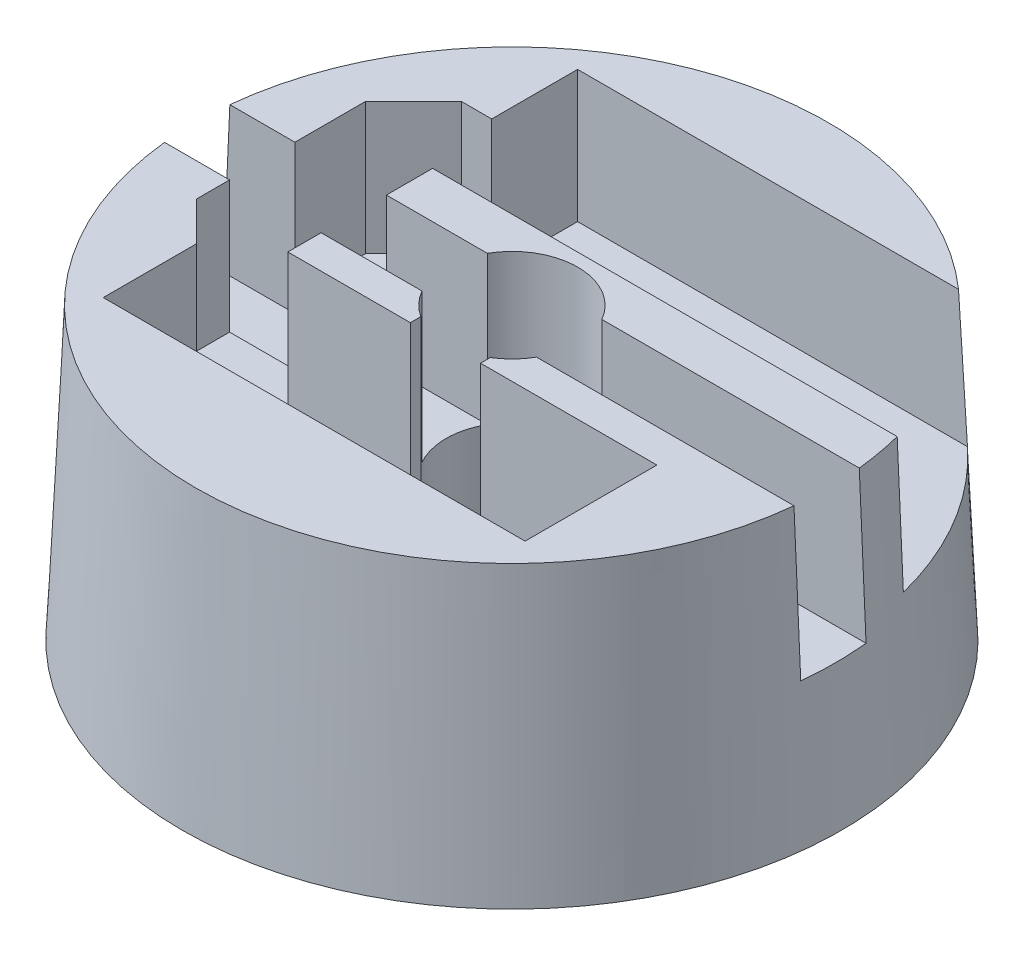
from build123d import *

# Parameters (mm, degrees)
SKETCH_2_R          = 12
SKETCH_1_R          = 12.5
CUT_EXTRUDE_1_DEPTH = 12.0000001
SKETCH_5_W          = 13
SKETCH_5_H          = 6
CUT_EXTRUDE_2_DEPTH = 5
SKETCH_6_W          = 2.476692414
SKETCH_6_H          = 6.83521307
CUT_EXTRUDE_3_DEPTH = 20
CUT_EXTRUDE_4_DEPTH = 5


with BuildPart() as part:
    # 草图2 → 放样1 section 0
    with BuildSketch(Plane(origin=(0, 11, 0), x_dir=(1, 0, 0), z_dir=(0, 1, 0))):
        Circle(SKETCH_2_R)
    # 草图1 → 放样1 section 1
    with BuildSketch(Plane(origin=(0, 0, 0), x_dir=(1, 0, 0), z_dir=(0, 1, 0))):
        Circle(SKETCH_1_R)
    loft()

    # 草图4 → 切除-拉伸1 (cut, through all)
    with BuildSketch(Plane(origin=(0, 0, 0), x_dir=(1, 0, 0), z_dir=(0, 1, 0))):
        with BuildLine():
            Line((-1.352272566, -2.5), (-1.352272566, -2.102702762))
            ThreePointArc((-1.352272566, -2.102702762), (0.025010963, 2.499874887), (1.309931483, -2.12933781))
            Line((1.309931483, -2.12933781), (1.309931483, -2.5))
            Line((1.309931483, -2.5), (8, -2.5))
            Line((8, -2.5), (8, -7.5))
            Line((8, -7.5), (-8, -7.5))
            Line((-8, -7.5), (-8, -2.5))
            Line((-8, -2.5), (-1.352272566, -2.5))
        make_face()
    extrude(amount=CUT_EXTRUDE_1_DEPTH, mode=Mode.SUBTRACT)

    # 草图5 → 切除-拉伸2 (cut)
    with BuildSketch(Plane(origin=(0, 11, 0), x_dir=(1, 0, 0), z_dir=(0, 1, 0))):
        with Locations((0, 5.991032562)):
            Rectangle(SKETCH_5_W, SKETCH_5_H)
        with BuildLine():
            Line((7.947410488, 8.991032562), (6.5, 8.991032562))
            Line((6.5, 8.991032562), (6.5, 2.991032562))
            Line((6.5, 2.991032562), (11.621261731, 2.991032562))
            ThreePointArc((11.621261731, 2.991032562), (10.233925596, 6.266320045), (7.947410488, 8.991032562))
        make_face()
        with BuildLine():
            Line((15.348611284, 8.991032562), (7.947410488, 8.991032562))
            ThreePointArc((7.947410488, 8.991032562), (10.233925596, 6.266320045), (11.621261731, 2.991032562))
            Line((11.621261731, 2.991032562), (15.348611284, 2.991032562))
            Line((15.348611284, 2.991032562), (15.348611284, 8.991032562))
        make_face()
    extrude(amount=-CUT_EXTRUDE_2_DEPTH, mode=Mode.SUBTRACT)

    # 草图6 → 切除-拉伸3 (cut, symmetric)
    with BuildSketch(Plane(origin=(0, 0, 0), x_dir=(0, 0, -1), z_dir=(1, 0, 0))):
        with Locations((0, 8.790545757)):
            Rectangle(SKETCH_6_W, SKETCH_6_H)
    extrude(amount=CUT_EXTRUDE_3_DEPTH, both=True, mode=Mode.SUBTRACT)

    # 草图7 → 切除-拉伸4 (cut)
    with BuildSketch(Plane(origin=(0, 11, 0), x_dir=(1, 0, 0), z_dir=(0, 1, 0))):
        Polygon((-5.998196858, 2.991032562), (-5.998196858, -3.96939498), (-8, -3.96939498), (-9.46939498, -2.5), (-9.46939498, 3.910589128), (-7.645587141, 5.734396966), (-6.5, 5.734396966), align=None)
    extrude(amount=-CUT_EXTRUDE_4_DEPTH, mode=Mode.SUBTRACT)


solid = part.part
